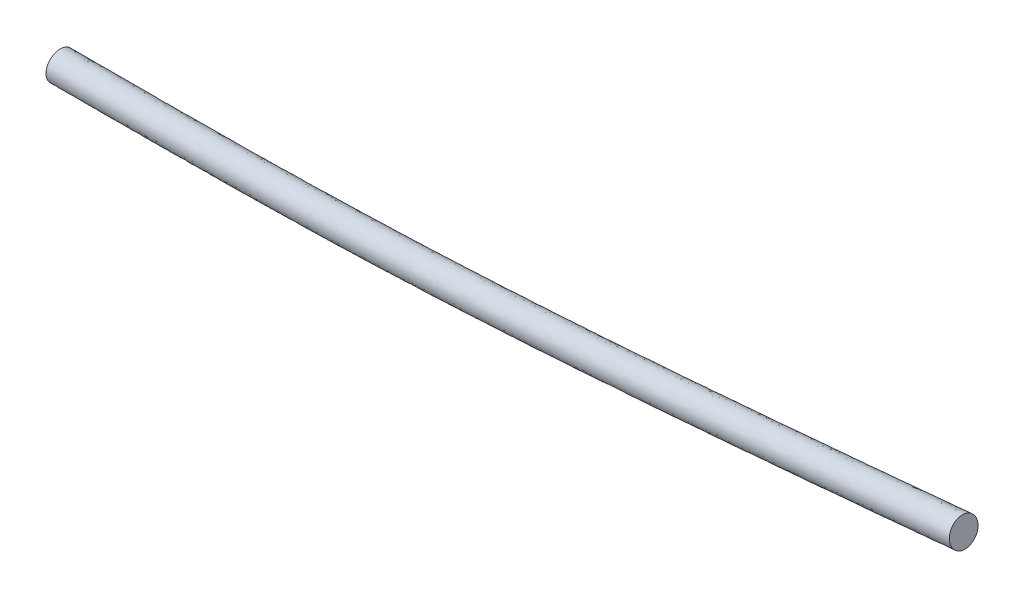
from build123d import *

# Parameters (mm, degrees)
SKETCH2_R = 1.5


with BuildPart() as part:
    # Sweep1: sweep along a path in Sketch1
    with BuildLine(Plane.XY) as sweep1_path:
        add(Edge.make_bspline(
            [(0, 0), (31.444677622, 0), (45.528224312, 0.332246131), (94.99434518, 5)],
            knots=[0, 0, 0, 0, 1, 1, 1, 1], degree=3))
    # Sketch2 → Sweep1 (sweep)
    with BuildSketch(Plane(origin=(0, 0, 0), x_dir=(0, 0, -1), z_dir=(1, 0, 0))):
        with Locations((0, 1.5)):
            Circle(SKETCH2_R)
    sweep(path=sweep1_path.line)


solid = part.part
